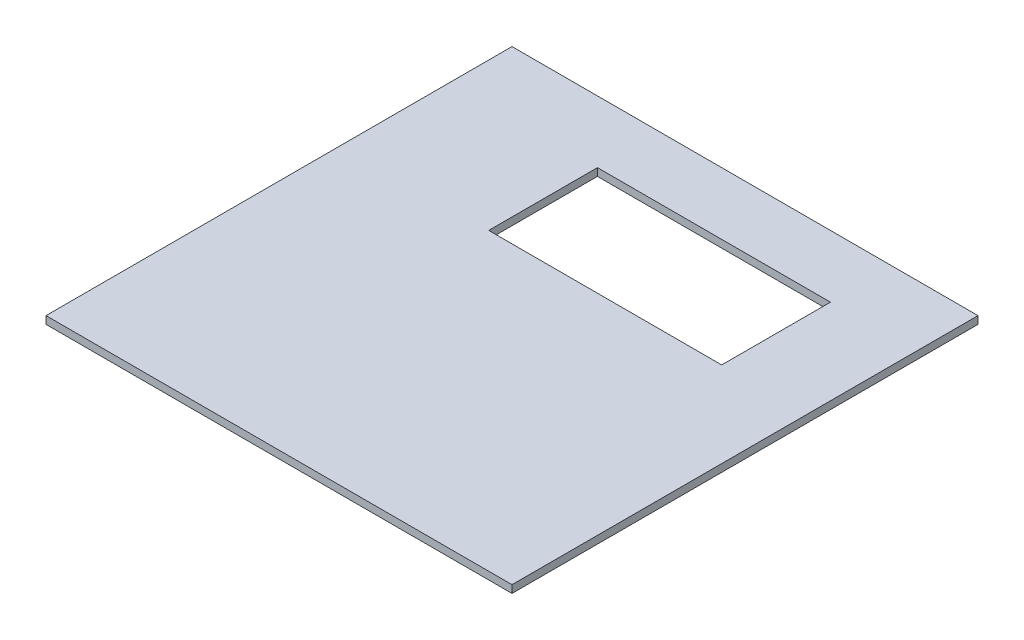
from build123d import *

# Parameters (mm, degrees)
SKETCH1_W           = 381
SKETCH1_H           = 381
BOSS_EXTRUDE1_DEPTH = 6.223
SKETCH4_W           = 190.5
SKETCH4_H           = 88.9
CUT_EXTRUDE1_DEPTH  = 203.2


with BuildPart() as part:
    # Sketch1 → Boss-Extrude1 (new body)
    with BuildSketch(Plane(origin=(0, 0, 0), x_dir=(1, 0, 0), z_dir=(0, 1, 0))):
        with Locations((190.5, 190.5)):
            Rectangle(SKETCH1_W, SKETCH1_H)
    extrude(amount=BOSS_EXTRUDE1_DEPTH)

    # Sketch4 → Cut-Extrude1 (cut)
    with BuildSketch(Plane(origin=(0, 6.223, 0), x_dir=(1, 0, 0), z_dir=(0, 1, 0))):
        with Locations((215.9, 285.75)):
            Rectangle(SKETCH4_W, SKETCH4_H)
    extrude(amount=-CUT_EXTRUDE1_DEPTH, mode=Mode.SUBTRACT)


solid = part.part
